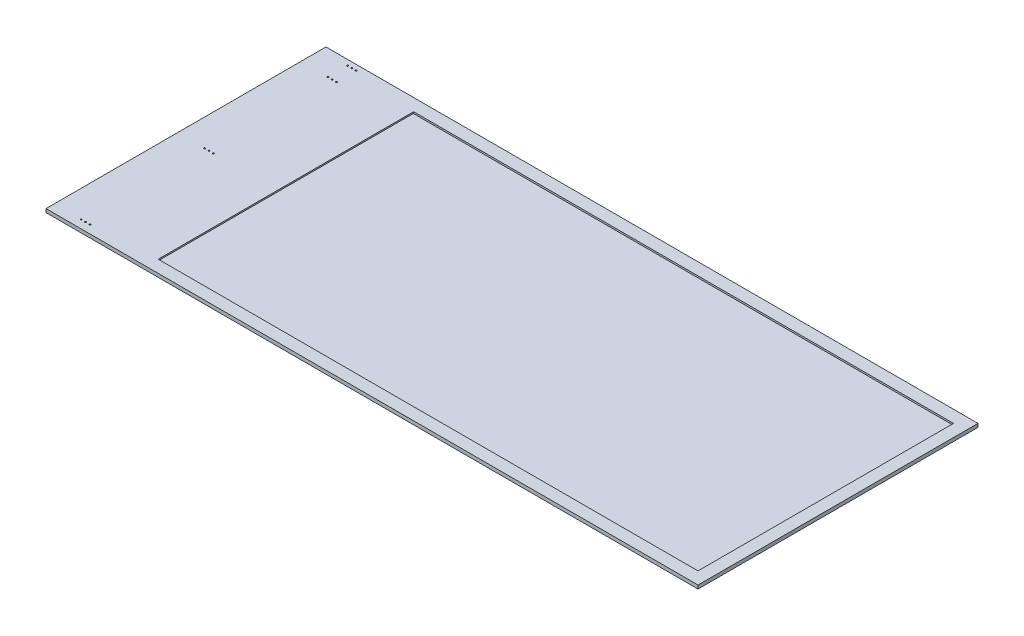
from build123d import *

# Parameters (mm, degrees)
SKETCH1_W           = 1066.8
SKETCH1_H           = 508
BOSS_EXTRUDE1_DEPTH = 6.35
SKETCH2_W           = 919.1625
SKETCH2_H           = 463.55
CUT_EXTRUDE1_DEPTH  = 3.175
SKETCH3_R           = 1.3589
CUT_EXTRUDE2_DEPTH  = 7.35
SKETCH5_W           = 55.9181
SKETCH5_H           = 463.55
BOSS_EXTRUDE2_DEPTH = 2.54
SKETCH6_W           = 116.2812
SKETCH6_H           = 508
BOSS_EXTRUDE3_DEPTH = 6.35
SKETCH7_W           = 116.2812
SKETCH7_H           = 463.55
CUT_EXTRUDE3_DEPTH  = 3.175


with BuildPart() as part:
    # Sketch1 → Boss-Extrude1 (new body)
    with BuildSketch(Plane(origin=(0, 0, 0), x_dir=(1, 0, 0), z_dir=(0, 1, 0))):
        with Locations((533.4, 254)):
            Rectangle(SKETCH1_W, SKETCH1_H)
    extrude(amount=BOSS_EXTRUDE1_DEPTH)

    # Sketch2 → Cut-Extrude1 (cut)
    with BuildSketch(Plane(origin=(0, 6.35, 0), x_dir=(1, 0, 0), z_dir=(0, 1, 0))):
        with Locations((584.99375, 254)):
            Rectangle(SKETCH2_W, SKETCH2_H)
    extrude(amount=-CUT_EXTRUDE1_DEPTH, mode=Mode.SUBTRACT)

    # Sketch3 → Cut-Extrude2 (cut, through all)
    with BuildSketch(Plane(origin=(0, 6.35, 0), x_dir=(1, 0, 0), z_dir=(0, 1, 0))):
        with Locations((49.149, 462.4832)):
            Circle(SKETCH3_R)
        with Locations((49.149, 498.094)):
            Circle(SKETCH3_R)
        with Locations((56.8452, 498.094)):
            Circle(SKETCH3_R)
        with Locations((56.8452, 462.4832)):
            Circle(SKETCH3_R)
        with Locations((64.5414, 498.094)):
            Circle(SKETCH3_R)
        with Locations((64.5414, 462.4832)):
            Circle(SKETCH3_R)
        with Locations((49.149, 14.8082)):
            Circle(SKETCH3_R)
        with Locations((57.0992, 14.8082)):
            Circle(SKETCH3_R)
        with Locations((65.0494, 14.8082)):
            Circle(SKETCH3_R)
        with Locations((49.149, 238.6457)):
            Circle(SKETCH3_R)
        with Locations((57.0992, 238.6457)):
            Circle(SKETCH3_R)
        with Locations((65.0494, 238.6457)):
            Circle(SKETCH3_R)
    extrude(amount=-CUT_EXTRUDE2_DEPTH, mode=Mode.SUBTRACT)

    # Sketch5 → Boss-Extrude2 (add)
    with BuildSketch(Plane(origin=(0, 6.35, 0), x_dir=(1, 0, 0), z_dir=(0, 1, 0))):
        with Locations((153.37155, 254)):
            Rectangle(SKETCH5_W, SKETCH5_H)
    extrude(amount=-BOSS_EXTRUDE2_DEPTH)

    # Sketch6 → Boss-Extrude3 (add)
    with BuildSketch(Plane(origin=(0, 6.35, 0), x_dir=(1, 0, 0), z_dir=(0, 1, 0))):
        with Locations((1124.9406, 254)):
            Rectangle(SKETCH6_W, SKETCH6_H)
    extrude(amount=-BOSS_EXTRUDE3_DEPTH)

    # Sketch7 → Cut-Extrude3 (cut)
    with BuildSketch(Plane(origin=(0, 6.35, 0), x_dir=(1, 0, 0), z_dir=(0, 1, 0))):
        with Locations((1102.7156, 254)):
            Rectangle(SKETCH7_W, SKETCH7_H)
    extrude(amount=-CUT_EXTRUDE3_DEPTH, mode=Mode.SUBTRACT)


solid = part.part
